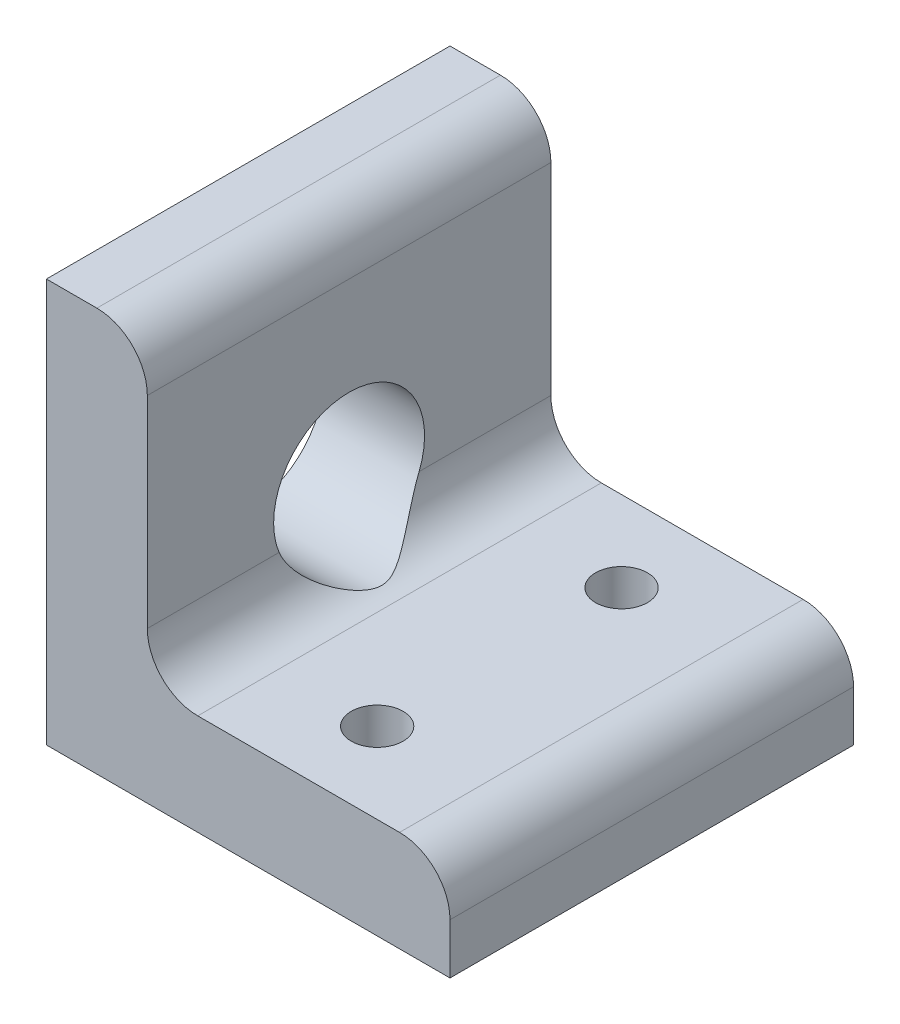
from build123d import *

# Parameters (mm, degrees)
BOSS_EXTRUDE1_DEPTH          = 25.4
F_4_CLEARANCE_HOLE1_D        = 3.2639
FILLET1_R                    = 3.175
F_3_8_0_374_DIAMETER_HOLE1_D = 9.4996


with BuildPart() as part:
    # Sketch1 → Boss-Extrude1 (new body)
    with BuildSketch(Plane.XY):
        Polygon((0, 25.4), (0, 0), (25.4, 0), (25.4, 6.35), (6.35, 6.35), (6.35, 25.4), align=None)
    extrude(amount=BOSS_EXTRUDE1_DEPTH)

    # #4 Clearance Hole1 (through all)
    with Locations(Plane(origin=(0, 6.35, 0), x_dir=(1, 0, 0), z_dir=(0, 1, 0))):
        with Locations((15.735159407, -20.32), (15.875, -5.08)):
            Hole(F_4_CLEARANCE_HOLE1_D / 2)

    # Fillet1
    fillet1_edges = [part.edges().sort_by_distance(p)[0] for p in [
        (6.35, 6.35, 12.7),
        (25.4, 6.35, 12.7),
        (6.35, 25.4, 12.7),
    ]]
    fillet(fillet1_edges, radius=FILLET1_R)

    # 3/8 (0.374) Diameter Hole1 (through all)
    with Locations(Plane(origin=(0, 0, 0), x_dir=(0, 0, -1), z_dir=(-1, 0, 0))):
        with Locations((-12.7, -11.303)):
            Hole(F_3_8_0_374_DIAMETER_HOLE1_D / 2)


solid = part.part
